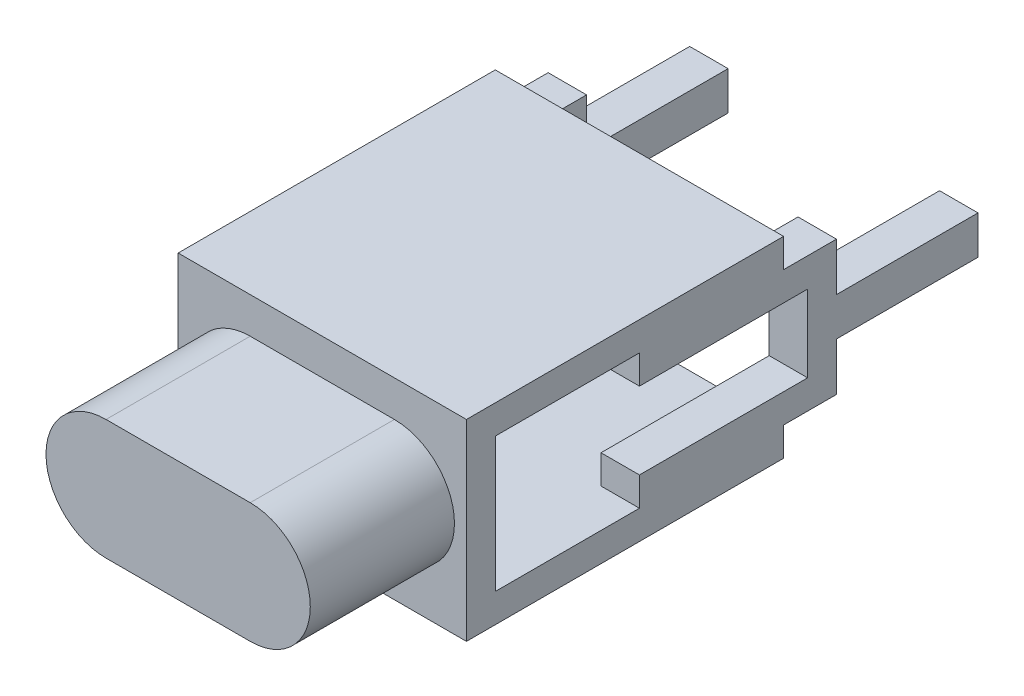
from build123d import *

# Parameters (mm, degrees)
SKETCH_1_R             = 7
EXTRUDE_1_DEPTH        = 160
EXTRUDE_1_DEPTH_BACK   = 36
SKETCH_2_R             = 7
EXTRUDE_2_DEPTH        = 8
SKETCH_3_W             = 18
SKETCH_3_H             = 11
EXTRUDE_3_DEPTH        = 15
EXTRUDE_4_DEPTH        = 30
SKETCH_5_W             = 60
SKETCH_5_H             = 40
EXTRUDE_5_DEPTH        = 6
SKETCH_6_W             = 60
SKETCH_6_H             = 6
EXTRUDE_6_DEPTH        = 60
SKETCH_7_W             = 29.455878384
SKETCH_7_H             = 4
EXTRUDE_7_DEPTH        = 8
PATTERN_LINEAR_1_COUNT = 2
PATTERN_LINEAR_1_PITCH = 52
SKETCH_8_W             = 71.56654599
SKETCH_8_H             = 41.958718016
CUT_EXTRUDE_1_DEPTH    = 300


with BuildPart() as part:
    # 草图1 → 凸台-拉伸1 (new body, two sides)
    with BuildSketch(Plane.XY) as extrude_1_sk:
        Circle(SKETCH_1_R)
    extrude(amount=EXTRUDE_1_DEPTH)
    extrude(extrude_1_sk.sketch, amount=-EXTRUDE_1_DEPTH_BACK)

    # 草图2 → 凸台-拉伸2 (add)
    with BuildSketch(Plane(origin=(0, 0, -36), x_dir=(-1, 0, 0), z_dir=(0, 0, -1))):
        Polygon((20, 7.5), (15, 12.5), (-15, 12.5), (-20, 7.5), (-20, -7.5), (-15, -12.5), (15, -12.5), (20, -7.5), align=None)
        Circle(SKETCH_2_R, mode=Mode.SUBTRACT)
        Circle(SKETCH_2_R)
    extrude(amount=EXTRUDE_2_DEPTH)

    # 草图3 → 凸台-拉伸3 (add)
    with BuildSketch(Plane(origin=(0, 0, -44), x_dir=(-1, 0, 0), z_dir=(0, 0, -1))):
        Rectangle(SKETCH_3_W, SKETCH_3_H)
    extrude(amount=EXTRUDE_3_DEPTH)

    # 草图4 → 凸台-拉伸4 (add)
    with BuildSketch(Plane(origin=(0, 0, -59), x_dir=(-1, 0, 0), z_dir=(0, 0, -1))):
        with BuildLine():
            Line((-15, -12.5), (-15, 12.5))
            ThreePointArc((-15, 12.5), (-27.5, 0), (-15, -12.5))
        make_face()
        with BuildLine():
            ThreePointArc((-3.77502784, 5.5), (-8.385621722, 10.606601718), (-15, 12.5))
            Line((-15, 12.5), (-15, -12.5))
            ThreePointArc((-15, -12.5), (-8.385621722, -10.606601718), (-3.77502784, -5.5))
            Line((-3.77502784, -5.5), (-9, -5.5))
            Line((-9, -5.5), (-9, 5.5))
            Line((-9, 5.5), (-3.77502784, 5.5))
        make_face()
        with BuildLine():
            ThreePointArc((-2.5, 0), (-2.822928267, 2.822928267), (-3.77502784, 5.5))
            Line((-3.77502784, 5.5), (-9, 5.5))
            Line((-9, 5.5), (-9, -5.5))
            Line((-9, -5.5), (-3.77502784, -5.5))
            ThreePointArc((-3.77502784, -5.5), (-2.822928267, -2.822928267), (-2.5, 0))
        make_face()
        with BuildLine():
            ThreePointArc((3.77502784, -5.5), (2.5, 0), (3.77502784, 5.5))
            Line((3.77502784, 5.5), (-3.77502784, 5.5))
            ThreePointArc((-3.77502784, 5.5), (-2.822928267, 2.822928267), (-2.5, 0))
            ThreePointArc((-2.5, 0), (-2.822928267, -2.822928267), (-3.77502784, -5.5))
            Line((-3.77502784, -5.5), (3.77502784, -5.5))
        make_face()
        with BuildLine():
            Line((9, 5.5), (3.77502784, 5.5))
            ThreePointArc((3.77502784, 5.5), (2.5, 0), (3.77502784, -5.5))
            Line((3.77502784, -5.5), (9, -5.5))
            Line((9, -5.5), (9, 5.5))
        make_face()
        with BuildLine():
            Line((15, -12.5), (15, 12.5))
            ThreePointArc((15, 12.5), (8.385621722, 10.606601718), (3.77502784, 5.5))
            Line((3.77502784, 5.5), (9, 5.5))
            Line((9, 5.5), (9, -5.5))
            Line((9, -5.5), (3.77502784, -5.5))
            ThreePointArc((3.77502784, -5.5), (8.385621722, -10.606601718), (15, -12.5))
        make_face()
        with BuildLine():
            ThreePointArc((27.5, 0), (23.838834765, 8.838834765), (15, 12.5))
            Line((15, 12.5), (15, -12.5))
            ThreePointArc((15, -12.5), (23.838834765, -8.838834765), (27.5, 0))
        make_face()
        with BuildLine():
            Line((-15, -12.5), (15, -12.5))
            ThreePointArc((15, -12.5), (8.385621722, -10.606601718), (3.77502784, -5.5))
            Line((3.77502784, -5.5), (-3.77502784, -5.5))
            ThreePointArc((-3.77502784, -5.5), (-8.385621722, -10.606601718), (-15, -12.5))
        make_face()
        with BuildLine():
            ThreePointArc((3.77502784, 5.5), (8.385621722, 10.606601718), (15, 12.5))
            Line((15, 12.5), (-15, 12.5))
            ThreePointArc((-15, 12.5), (-8.385621722, 10.606601718), (-3.77502784, 5.5))
            Line((-3.77502784, 5.5), (3.77502784, 5.5))
        make_face()
    extrude(amount=EXTRUDE_4_DEPTH)

    # 草图5 → 凸台-拉伸5 (add)
    with BuildSketch(Plane(origin=(0, 0, -89), x_dir=(-1, 0, 0), z_dir=(0, 0, -1))):
        Rectangle(SKETCH_5_W, SKETCH_5_H)
    extrude(amount=EXTRUDE_5_DEPTH)

    # 草图6 → 凸台-拉伸6 (add)
    with BuildSketch(Plane(origin=(0, 0, -95), x_dir=(-1, 0, 0), z_dir=(0, 0, -1))):
        with Locations((0, 17)):
            Rectangle(SKETCH_6_W, SKETCH_6_H)
        with Locations((0, -17)):
            Rectangle(SKETCH_6_W, SKETCH_6_H)
    extrude(amount=EXTRUDE_6_DEPTH)

    # 草图7 → 凸台-拉伸7 (add)
    with BuildSketch(Plane.ZY.offset(30)):
        Polygon((-125, 8), (-125, 14), (-155, 14), (-160, 14), (-160, 8), align=None)
        Polygon((-125, -8), (-160, -8), (-160, -14), (-155, -14), (-125, -14), align=None)
        Polygon((-160, 8), (-160, 14), (-166, 14), (-166, 4), (-166, 0), (-166, -4), (-166, -14), (-160, -14), (-160, -8), align=None)
        with Locations((-180.727939192, -2)):
            Rectangle(SKETCH_7_W, SKETCH_7_H)
        with Locations((-180.727939192, 2)):
            Rectangle(SKETCH_7_W, SKETCH_7_H)
    extrude_7 = extrude(amount=-EXTRUDE_7_DEPTH)

    # 阵列(线性)1: 凸台-拉伸7 ×2
    with Locations(*[(i * PATTERN_LINEAR_1_PITCH, 0, 0) for i in range(1, PATTERN_LINEAR_1_COUNT)]):
        add(extrude_7)

    # 草图8 → 切除-拉伸1 (cut)
    with BuildSketch(Plane.XY.offset(-59)):
        Rectangle(SKETCH_8_W, SKETCH_8_H)
    extrude(amount=CUT_EXTRUDE_1_DEPTH, mode=Mode.SUBTRACT)


solid = part.part
